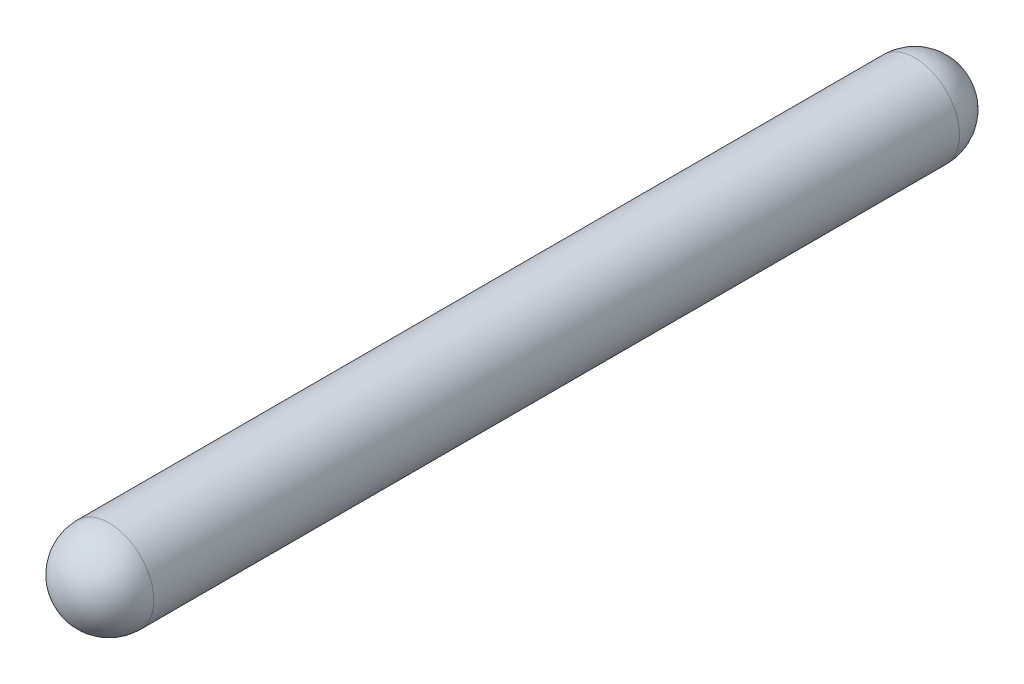
from build123d import *

# Parameters (mm, degrees)
SKETCH1_R           = 1.5
BOSS_EXTRUDE1_DEPTH = 30
FILLET1_R           = 1.5
SCALE1_SCALE        = 2


with BuildPart() as part:
    # Sketch1 → Boss-Extrude1 (new body)
    with BuildSketch(Plane.XY):
        Circle(SKETCH1_R)
    extrude(amount=BOSS_EXTRUDE1_DEPTH)

    # Fillet1
    fillet1_edges = [part.edges().sort_by_distance(p)[0] for p in [
        (-1.5, 0, 0),
        (-1.5, 0, 30),
    ]]
    fillet(fillet1_edges, radius=FILLET1_R)


with BuildPart() as part_1:
    # Scale1: scaled about (0, 0, 15)
    add(part.part.scale(SCALE1_SCALE).moved(Location((0, 0, -15))))


solid = part_1.part
